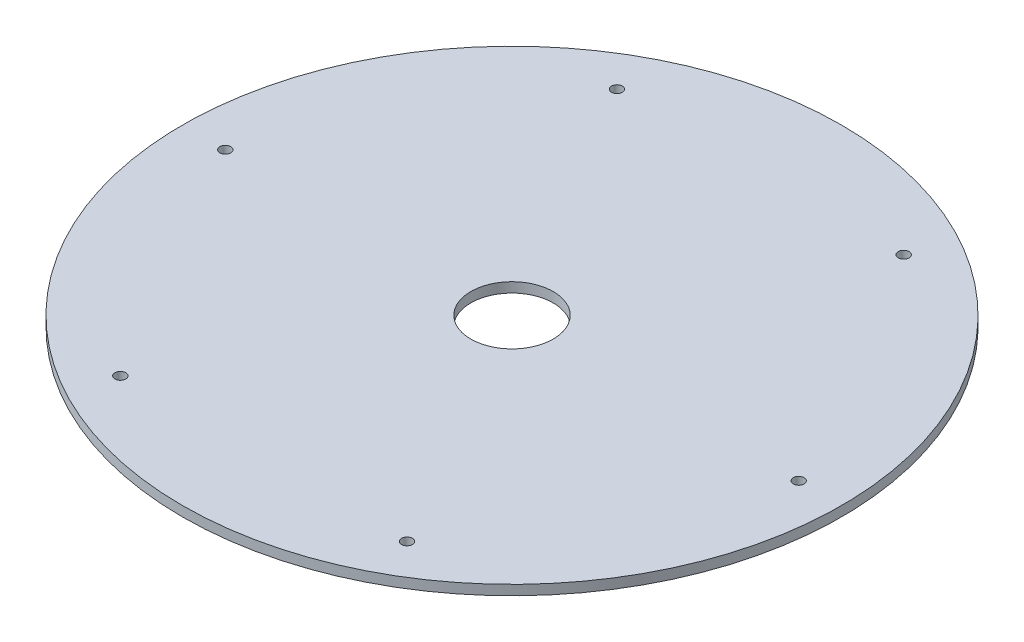
from build123d import *

# Parameters (mm, degrees)
SKETCH1_R           = 100
SKETCH1_R_2         = 1.65
BOSS_EXTRUDE1_DEPTH = 3
SKETCH2_R           = 12.5
CUT_EXTRUDE1_DEPTH  = 4


with BuildPart() as part:
    # Sketch1 → Boss-Extrude1 (new body)
    with BuildSketch(Plane(origin=(0, 0, 0), x_dir=(1, 0, 0), z_dir=(0, 1, 0))):
        Circle(SKETCH1_R)
        with Locations((-87, 0)):
            Circle(SKETCH1_R_2, mode=Mode.SUBTRACT)
        with Locations((-43.5, 75.344210129)):
            Circle(SKETCH1_R_2, mode=Mode.SUBTRACT)
        with Locations((43.5, 75.344210129)):
            Circle(SKETCH1_R_2, mode=Mode.SUBTRACT)
        with Locations((87, 0)):
            Circle(SKETCH1_R_2, mode=Mode.SUBTRACT)
        with Locations((43.5, -75.344210129)):
            Circle(SKETCH1_R_2, mode=Mode.SUBTRACT)
        with Locations((-43.5, -75.344210129)):
            Circle(SKETCH1_R_2, mode=Mode.SUBTRACT)
    extrude(amount=BOSS_EXTRUDE1_DEPTH)

    # Sketch2 → Cut-Extrude1 (cut, through all)
    with BuildSketch(Plane(origin=(0, 3, 0), x_dir=(1, 0, 0), z_dir=(0, 1, 0))):
        Circle(SKETCH2_R)
    extrude(amount=-CUT_EXTRUDE1_DEPTH, mode=Mode.SUBTRACT)


solid = part.part
